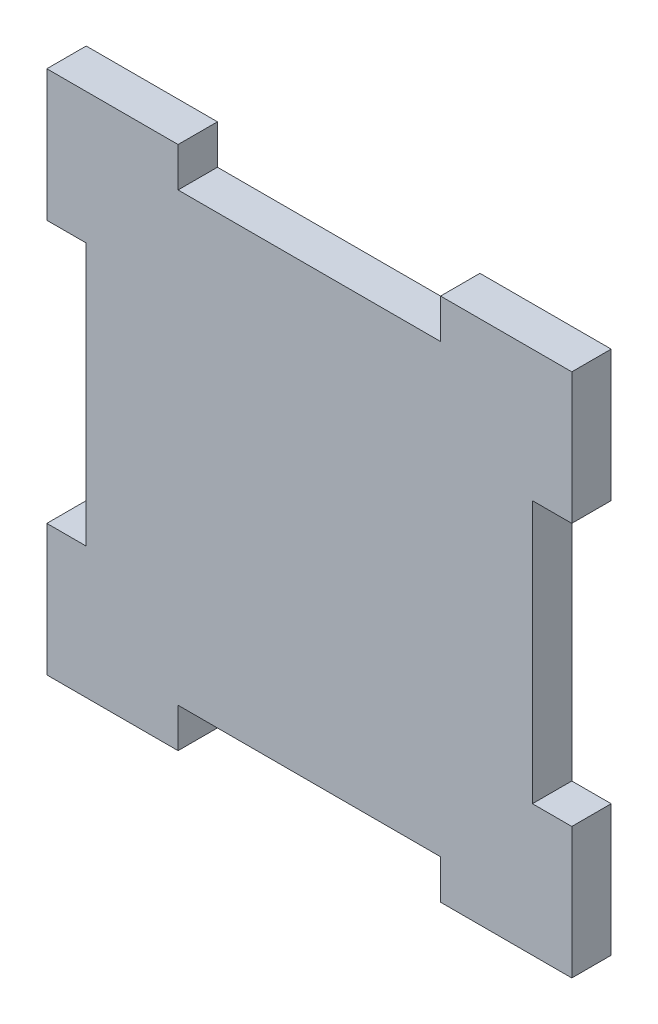
from build123d import *

# Parameters (mm, degrees)
SALIENTE_EXTRUIR1_DEPTH = 3


with BuildPart() as part:
    # Croquis1 → Saliente-Extruir1 (new body)
    with BuildSketch(Plane.XY):
        Polygon((-42.440693286, -22.897473621), (-42.440693286, -25.897473621), (-22.440693286, -25.897473621), (-22.440693286, -22.897473621), (-12.440693286, -22.897473621), (-12.440693286, -32.897473621), (-15.440693286, -32.897473621), (-15.440693286, -52.897473621), (-12.440693286, -52.897473621), (-12.440693286, -62.897473621), (-22.440693286, -62.897473621), (-22.440693286, -59.897473621), (-42.440693286, -59.897473621), (-42.440693286, -62.897473621), (-52.440693286, -62.897473621), (-52.440693286, -52.897473621), (-49.440693286, -52.897473621), (-49.440693286, -32.897473621), (-52.440693286, -32.897473621), (-52.440693286, -22.897473621), align=None)
    extrude(amount=SALIENTE_EXTRUIR1_DEPTH)


solid = part.part
